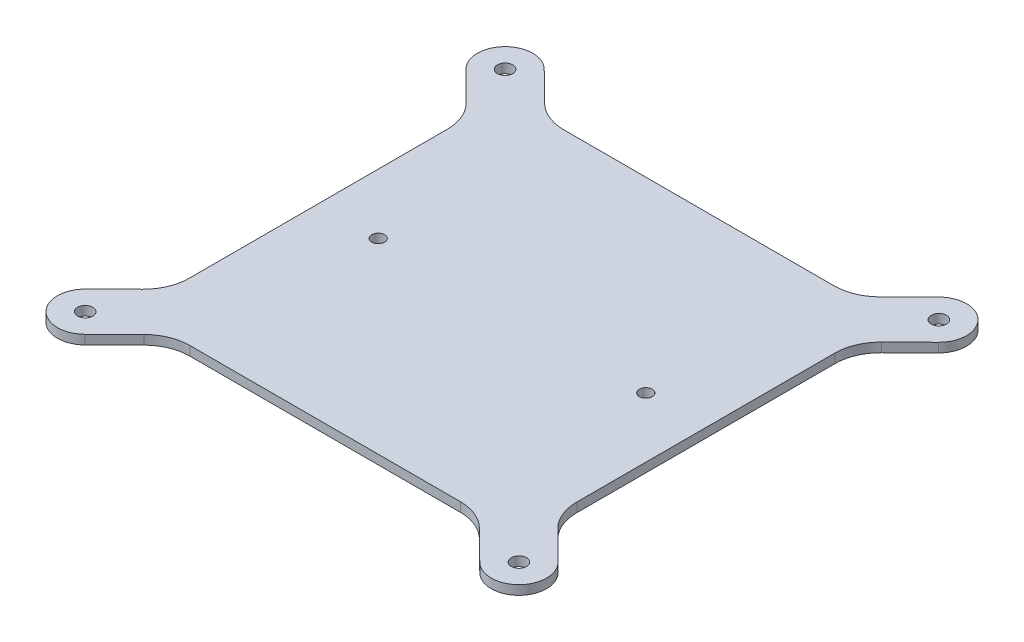
from build123d import *

# Parameters (mm, degrees)
SKETCH1_W               = 84
SKETCH1_H               = 81
BOSS_EXTRUDE1_DEPTH     = 2
SKETCH2_R               = 1.65
BOSS_EXTRUDE2_DEPTH     = 2
MIRROR2_COPY_1_SKETCH_R = 1.65
MIRROR2_COPY_1_DEPTH    = 2
FILLET1_R               = 10
SKETCH3_R               = 1.4
CUT_EXTRUDE1_DEPTH      = 3


with BuildPart() as part:
    # Sketch1 → Boss-Extrude1 (new body)
    with BuildSketch(Plane(origin=(0, 0, 0), x_dir=(1, 0, 0), z_dir=(0, 1, 0))):
        Rectangle(SKETCH1_W, SKETCH1_H)
    extrude(amount=BOSS_EXTRUDE1_DEPTH)

    # Sketch2 → Boss-Extrude2 (add)
    with BuildSketch(Plane(origin=(0, 2, 0), x_dir=(1, 0, 0), z_dir=(0, 1, 0))):
        with BuildLine():
            Line((-42.781426662, 49.766572276), (-32.781426662, 39.879072276))
            ThreePointArc((-32.781426662, 39.879072276), (-32.733427724, 31.393926662), (-41.218573338, 31.345927724))
            Line((-41.218573338, 31.345927724), (-51.218573338, 41.233427724))
            ThreePointArc((-51.218573338, 41.233427724), (-51.266572276, 49.718573338), (-42.781426662, 49.766572276))
        make_face()
        with Locations((-47, 45.5)):
            Circle(SKETCH2_R, mode=Mode.SUBTRACT)
    boss_extrude2 = extrude(amount=-BOSS_EXTRUDE2_DEPTH)

    # Mirror1: Boss-Extrude2 across plane
    add(boss_extrude2.mirror(Plane.XY))

    # Mirror2: Boss-Extrude2 across plane
    add(boss_extrude2.mirror(Plane(origin=(0, 0, 0), x_dir=(0, 0, 1), z_dir=(1, 0, 0))))

    # Mirror2 copy 1 sketch → Mirror2 copy 1 (add)
    with BuildSketch(Plane(origin=(0, 2, 0), x_dir=(-1, 0, 0), z_dir=(0, 1, 0))):
        with BuildLine():
            Line((-42.781426662, 49.766572276), (-32.781426662, 39.879072276))
            ThreePointArc((-32.781426662, 39.879072276), (-32.733427724, 31.393926662), (-41.218573338, 31.345927724))
            Line((-41.218573338, 31.345927724), (-51.218573338, 41.233427724))
            ThreePointArc((-51.218573338, 41.233427724), (-51.266572276, 49.718573338), (-42.781426662, 49.766572276))
        make_face()
        with Locations((-47, 45.5)):
            Circle(MIRROR2_COPY_1_SKETCH_R, mode=Mode.SUBTRACT)
    extrude(amount=-MIRROR2_COPY_1_DEPTH)

    # Fillet1
    fillet1_edges = [part.edges().sort_by_distance(p)[0] for p in [
        (-42, 1, -32.118563335),
        (-33.409419303, 1, -40.5),
        (-42, 1, 32.118563335),
        (-33.409419303, 1, 40.5),
        (42, 1, -32.118563335),
        (33.409419303, 1, -40.5),
        (42, 1, 32.118563335),
        (33.409419303, 1, 40.5),
    ]]
    fillet(fillet1_edges, radius=FILLET1_R)

    # Sketch3 → Cut-Extrude1 (cut, through all)
    with BuildSketch(Plane(origin=(0, 2, 0), x_dir=(1, 0, 0), z_dir=(0, 1, 0))):
        with Locations((-29, 0)):
            Circle(SKETCH3_R)
        with Locations((29, 0)):
            Circle(SKETCH3_R)
    extrude(amount=-CUT_EXTRUDE1_DEPTH, mode=Mode.SUBTRACT)


solid = part.part
